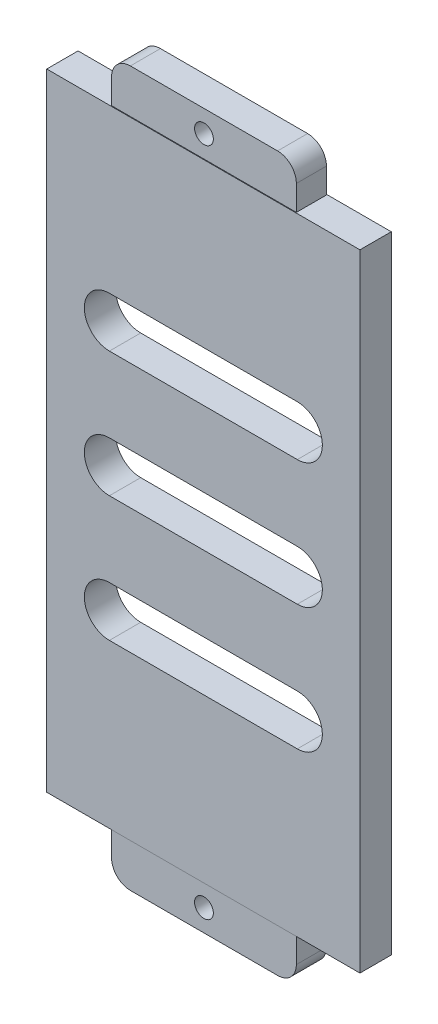
from build123d import *

# Parameters (mm, degrees)
SKETCH_1_W          = 50
SKETCH_1_H          = 100
EXTRUDE_1_DEPTH     = 5
SKETCH_2_W          = 29.5
SKETCH_2_H          = 2.4
EXTRUDE_2_DEPTH     = 7
SKETCH_3_W          = 29.5
SKETCH_3_H          = 2.4
EXTRUDE_3_DEPTH     = 7
CUT_EXTRUDE_1_DEPTH = 5
FILLET_1_R          = 3
SKETCH_5_R          = 1.5
CUT_EXTRUDE_2_DEPTH = 5.9
SKETCH_6_R          = 1.5
CUT_EXTRUDE_3_DEPTH = 5.9


with BuildPart() as part:
    # 草图1 → 凸台-拉伸1 (new body)
    with BuildSketch(Plane.XY):
        Rectangle(SKETCH_1_W, SKETCH_1_H)
    extrude(amount=-EXTRUDE_1_DEPTH)

    # 草图2 → 凸台-拉伸2 (add)
    with BuildSketch(Plane(origin=(0, 50, 0), x_dir=(1, 0, 0), z_dir=(0, 1, 0))):
        with Locations((0, 3.7)):
            Rectangle(SKETCH_2_W, SKETCH_2_H)
        with Locations((0, 1.3)):
            Rectangle(SKETCH_2_W, SKETCH_2_H)
    extrude(amount=EXTRUDE_2_DEPTH)

    # 草图3 → 凸台-拉伸3 (add)
    with BuildSketch(Plane.XZ.offset(50)):
        with Locations((0, -1.3)):
            Rectangle(SKETCH_3_W, SKETCH_3_H)
        with Locations((0, -3.7)):
            Rectangle(SKETCH_3_W, SKETCH_3_H)
    extrude(amount=EXTRUDE_3_DEPTH)

    # 草图4 → 切除-拉伸1 (cut)
    with BuildSketch(Plane.XY):
        with BuildLine():
            Line((0, 20), (0, 24))
            Line((0, 24), (-15, 24))
            ThreePointArc((-15, 24), (-17.828427125, 22.828427125), (-19, 20))
            Line((-19, 20), (0, 20))
        make_face()
        with BuildLine():
            Line((15, 24), (0, 24))
            Line((0, 24), (0, 20))
            Line((0, 20), (19, 20))
            ThreePointArc((19, 20), (17.828427125, 22.828427125), (15, 24))
        make_face()
        with BuildLine():
            Line((0, 16), (0, 20))
            Line((0, 20), (-19, 20))
            ThreePointArc((-19, 20), (-17.828427125, 17.171572875), (-15, 16))
            Line((-15, 16), (0, 16))
        make_face()
        with BuildLine():
            Line((19, 20), (0, 20))
            Line((0, 20), (0, 16))
            Line((0, 16), (15, 16))
            ThreePointArc((15, 16), (17.828427125, 17.171572875), (19, 20))
        make_face()
        with BuildLine():
            Line((0, 0), (0, 4))
            Line((0, 4), (-15, 4))
            ThreePointArc((-15, 4), (-17.828427125, 2.828427125), (-19, 0))
            Line((-19, 0), (0, 0))
        make_face()
        with BuildLine():
            Line((15, 4), (0, 4))
            Line((0, 4), (0, 0))
            Line((0, 0), (19, 0))
            ThreePointArc((19, 0), (17.828427125, 2.828427125), (15, 4))
        make_face()
        with BuildLine():
            Line((0, -4), (0, 0))
            Line((0, 0), (-19, 0))
            ThreePointArc((-19, 0), (-17.828427125, -2.828427125), (-15, -4))
            Line((-15, -4), (0, -4))
        make_face()
        with BuildLine():
            Line((19, 0), (0, 0))
            Line((0, 0), (0, -4))
            Line((0, -4), (15, -4))
            ThreePointArc((15, -4), (17.828427125, -2.828427125), (19, 0))
        make_face()
        with BuildLine():
            Line((0, -20), (0, -16))
            Line((0, -16), (-15, -16))
            ThreePointArc((-15, -16), (-17.828427125, -17.171572875), (-19, -20))
            Line((-19, -20), (0, -20))
        make_face()
        with BuildLine():
            Line((0, -24), (0, -20))
            Line((0, -20), (-19, -20))
            ThreePointArc((-19, -20), (-17.828427125, -22.828427125), (-15, -24))
            Line((-15, -24), (0, -24))
        make_face()
        with BuildLine():
            Line((15, -16), (0, -16))
            Line((0, -16), (0, -20))
            Line((0, -20), (19, -20))
            ThreePointArc((19, -20), (17.828427125, -17.171572875), (15, -16))
        make_face()
        with BuildLine():
            Line((19, -20), (0, -20))
            Line((0, -20), (0, -24))
            Line((0, -24), (15, -24))
            ThreePointArc((15, -24), (17.828427125, -22.828427125), (19, -20))
        make_face()
    extrude(amount=-CUT_EXTRUDE_1_DEPTH, mode=Mode.SUBTRACT)

    # 圆角1
    fillet_1_edges = [part.edges().sort_by_distance(p)[0] for p in [
        (14.75, 57, -2.5),
        (-14.75, 57, -2.5),
        (14.75, -57, -2.5),
        (-14.75, -57, -2.5),
    ]]
    fillet(fillet_1_edges, radius=FILLET_1_R)

    # 草图5 → 切除-拉伸2 (cut, through all)
    with BuildSketch(Plane.XY.offset(-0.1)):
        with Locations((0, 53.5)):
            Circle(SKETCH_5_R)
    extrude(amount=-CUT_EXTRUDE_2_DEPTH, mode=Mode.SUBTRACT)

    # 草图6 → 切除-拉伸3 (cut, through all)
    with BuildSketch(Plane.XY.offset(-0.1)):
        with Locations((0, -53.5)):
            Circle(SKETCH_6_R)
    extrude(amount=-CUT_EXTRUDE_3_DEPTH, mode=Mode.SUBTRACT)


solid = part.part
